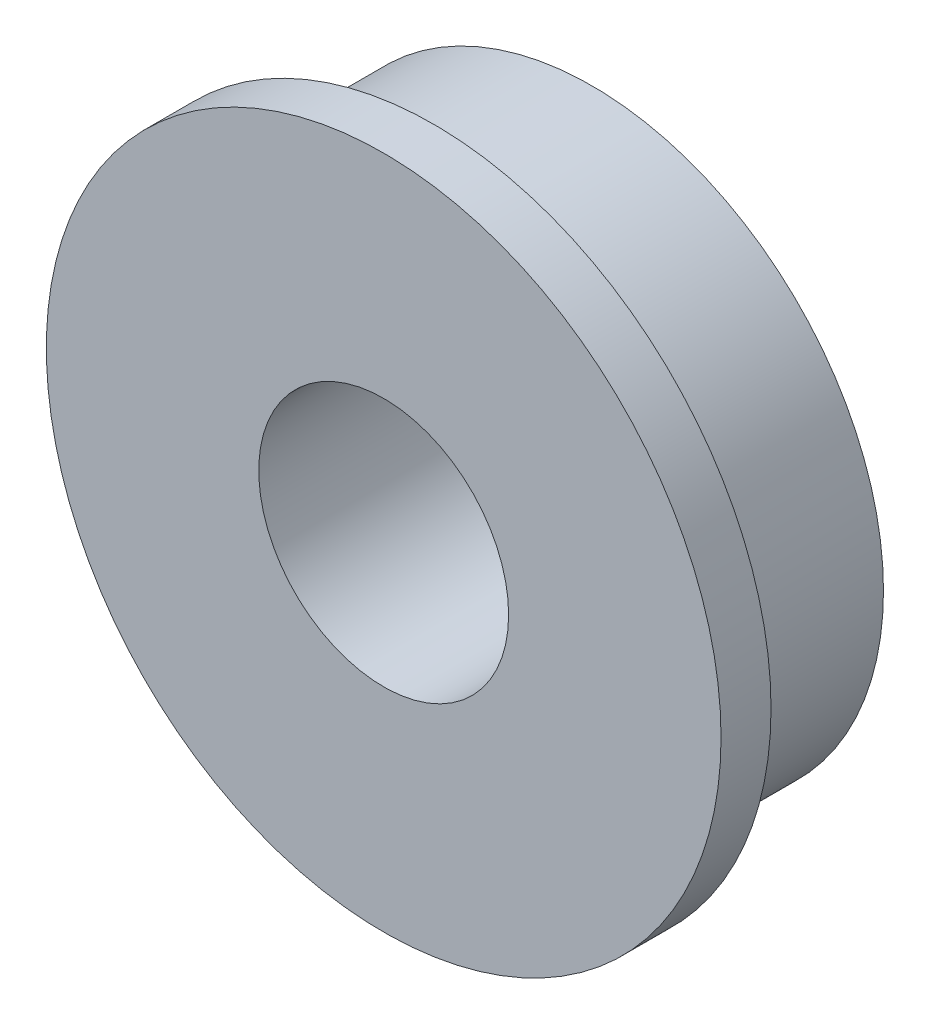
from build123d import *

# Parameters (mm, degrees)
SKETCH_1_R      = 3.5
SKETCH_1_R_2    = 1.5
EXTRUDE_1_DEPTH = 2.5
SKETCH_2_R      = 4.05
SKETCH_2_R_2    = 1.5
EXTRUDE_2_DEPTH = 0.6


with BuildPart() as part:
    # 草图1 → 凸台-拉伸1 (new body)
    with BuildSketch(Plane.XY):
        Circle(SKETCH_1_R)
        Circle(SKETCH_1_R_2, mode=Mode.SUBTRACT)
    extrude(amount=EXTRUDE_1_DEPTH)

    # 草图2 → 凸台-拉伸2 (add)
    with BuildSketch(Plane.XY.offset(2.5)):
        Circle(SKETCH_2_R)
        Circle(SKETCH_2_R_2, mode=Mode.SUBTRACT)
    extrude(amount=-EXTRUDE_2_DEPTH)


solid = part.part
